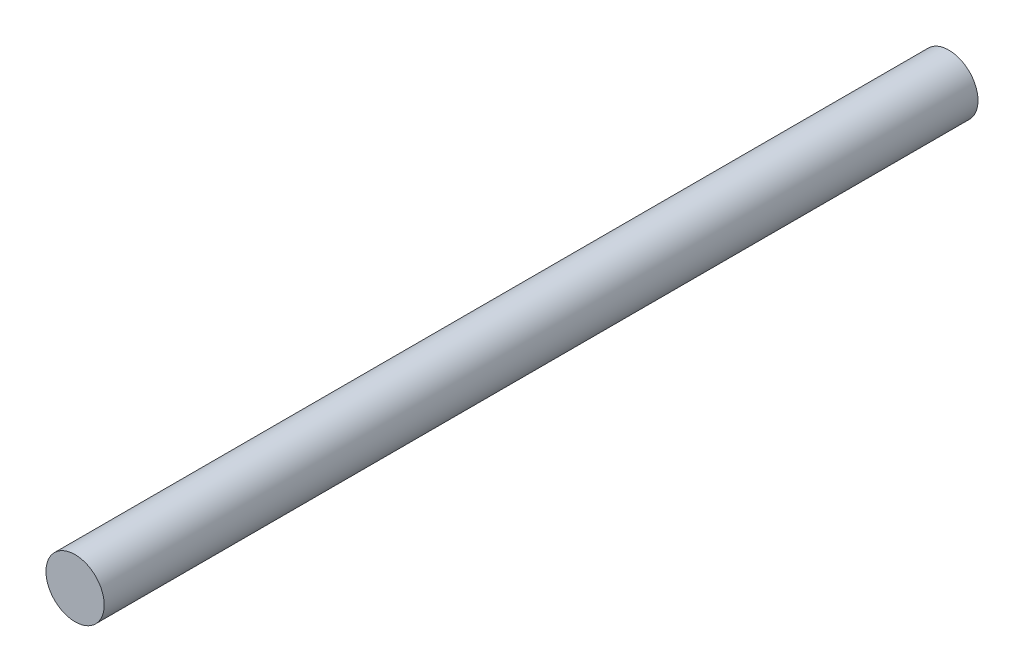
from build123d import *

# Parameters (mm, degrees)
ESBO_O1_R                = 5
RESSALTO_EXTRUS_O1_DEPTH = 150


with BuildPart() as part:
    # Esboço1 → Ressalto-extrusão1 (new body)
    with BuildSketch(Plane.XY):
        with Locations((-4.256859187, 1.586848558)):
            Circle(ESBO_O1_R)
    extrude(amount=RESSALTO_EXTRUS_O1_DEPTH)


solid = part.part
